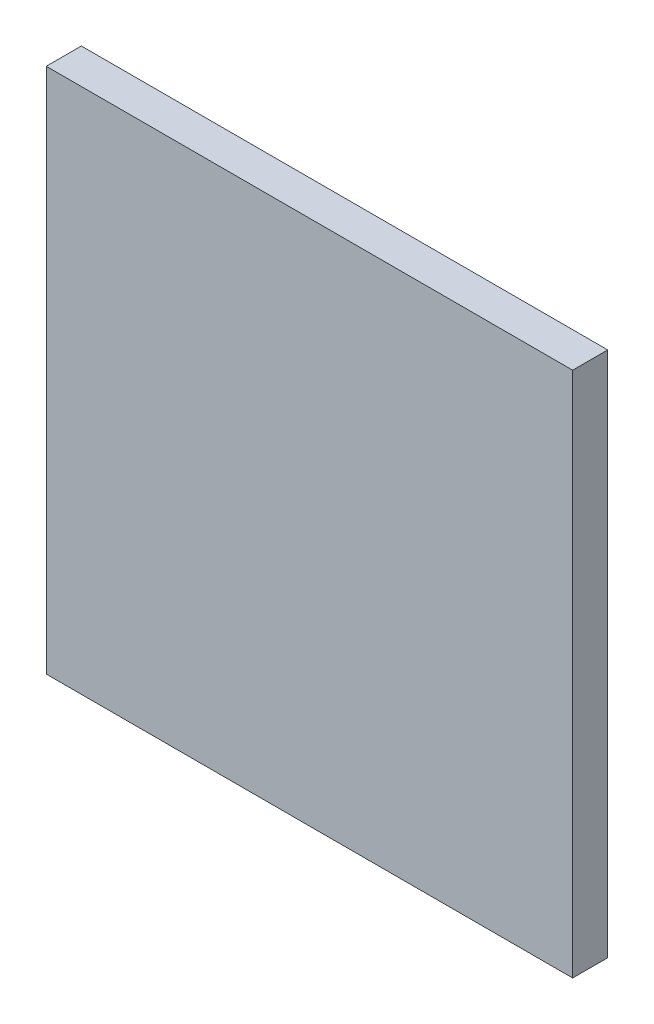
from build123d import *

# Parameters (mm, degrees)
IZIM1_W                     = 300
IZIM1_H                     = 300
Y_KSEKLIK_EKSTR_ZYON1_DEPTH = 20


with BuildPart() as part:
    # Çizim1 → Yükseklik-Ekstrüzyon1 (new body)
    with BuildSketch(Plane.XY):
        Rectangle(IZIM1_W, IZIM1_H)
    extrude(amount=-Y_KSEKLIK_EKSTR_ZYON1_DEPTH)


solid = part.part
